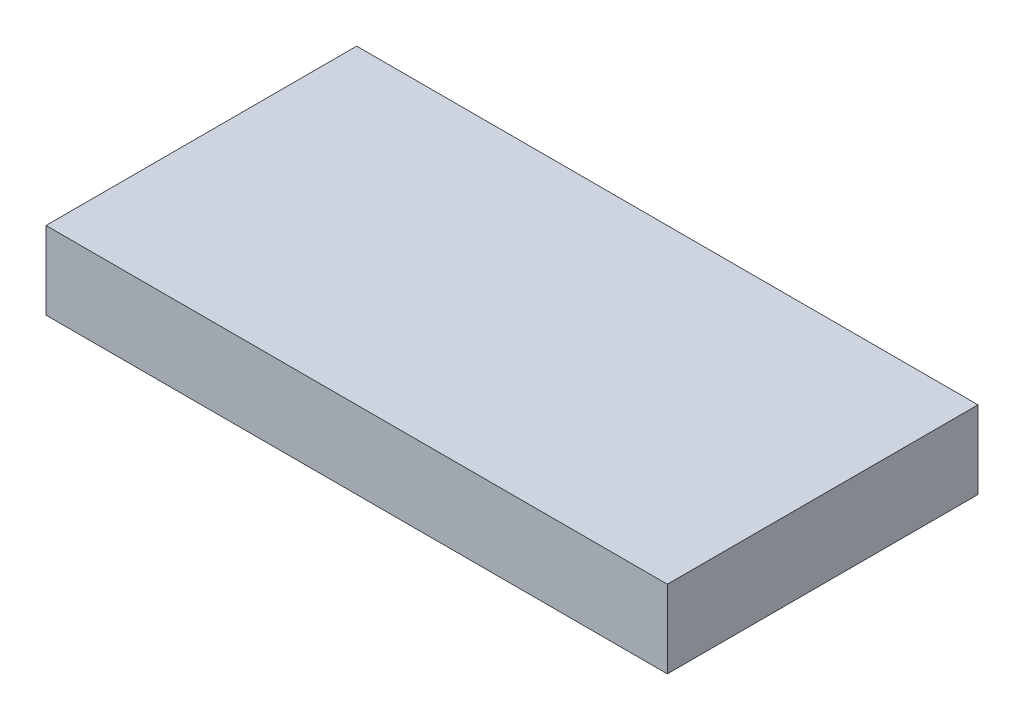
from build123d import *

# Parameters (mm, degrees)
SKETCH1_W           = 160
SKETCH1_H           = 80
BOSS_EXTRUDE1_DEPTH = 20


with BuildPart() as part:
    # Sketch1 → Boss-Extrude1 (new body)
    with BuildSketch(Plane(origin=(0, 0, 0), x_dir=(1, 0, 0), z_dir=(0, 1, 0))):
        with Locations((15.452991453, -10.051282051)):
            Rectangle(SKETCH1_W, SKETCH1_H)
    extrude(amount=BOSS_EXTRUDE1_DEPTH)


solid = part.part
